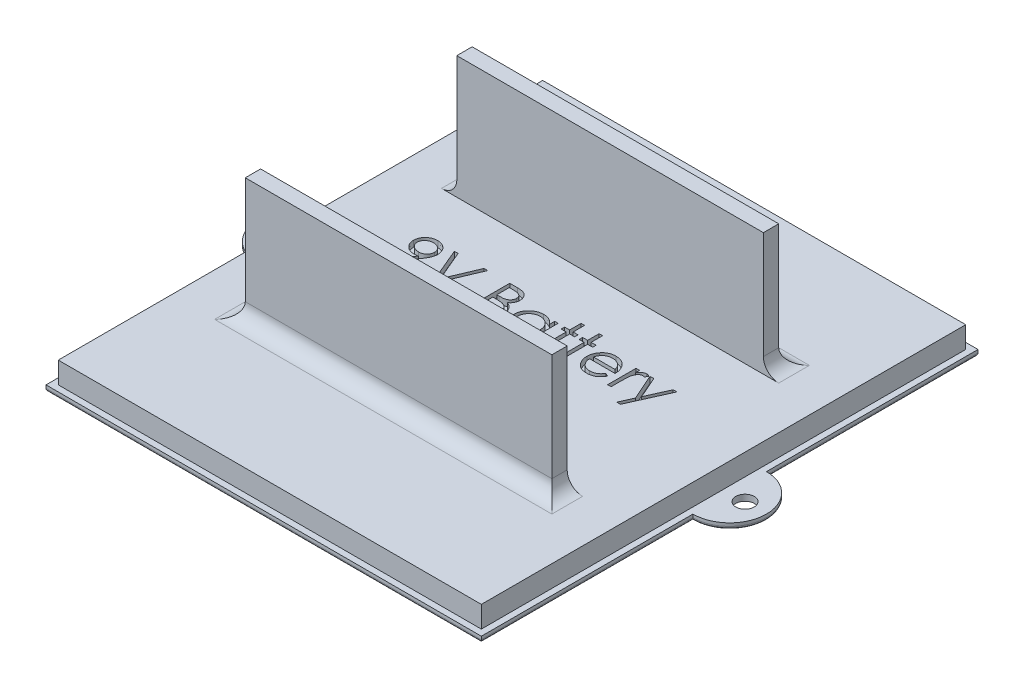
from build123d import *

# Parameters (mm, degrees)
SKETCH1_W            = 71
SKETCH1_H            = 81
BOSS_EXTRUDE1_DEPTH  = 4.5
TEXT_2_W             = 0.569871795
TEXT_2_H             = 6.512820513
CUT_EXTRUDE1_DEPTH   = 1
BOSS_EXTRUDE3_DEPTH  = 4.5
SKETCH5_R            = 1.5
CUT_EXTRUDE2_DEPTH   = 4.5
SKETCH61_W           = 89
SKETCH61_H           = 99
SKETCH61_W_2         = 69
SKETCH61_H_2         = 79
CUT_EXTRUDE21_DEPTH  = 3.5
SKETCH9_W            = 50
SKETCH9_H            = 2.5
TOP_TRACK_DEPTH      = 20
FILLET1_R            = 2.5
FILLET1_OF_MIRROR4_R = 2.5
FILLET2_R            = 0.5


with BuildPart() as part:
    # Sketch1 → Boss-Extrude1 (new body)
    with BuildSketch(Plane(origin=(0, 0, 0), x_dir=(1, 0, 0), z_dir=(0, 1, 0))):
        Rectangle(SKETCH1_W, SKETCH1_H)
    extrude(amount=BOSS_EXTRUDE1_DEPTH)

    # text 2 → Cut-Extrude1 (cut)
    with BuildSketch(Plane(origin=(0, 4.5, 0), x_dir=(1, 0, 0), z_dir=(0, 1, 0))):
        with BuildLine():
            Line((-21.152394286, 1.65489819), (-21.607782908, 1.971634969))
            Line((-21.607782908, 1.971634969), (-19.842197972, 4.552594504))
            add(Edge.make_bspline(
                [(-19.842197972, 4.552594504), (-19.954848307, 4.538818518), (-20.176663096, 4.511692833), (-20.400068981, 4.506709616), (-20.510016482, 4.504257164)],
                knots=[0, 0, 0, 0, 0.000340231, 0.000669933, 0.000669933, 0.000669933, 0.000669933], degree=3))
            add(Edge.make_bspline(
                [(-20.510016482, 4.504257164), (-20.576677054, 4.505964546), (-20.707525928, 4.509315987), (-20.899897641, 4.53588041), (-21.084747158, 4.576792785), (-21.261584418, 4.63784124), (-21.431074091, 4.71371142), (-21.592846171, 4.807794859), (-21.746682887, 4.918477702), (-21.890932045, 5.045174701), (-22.0221262, 5.184290596), (-22.139008468, 5.33153012), (-22.236147379, 5.488603667), (-22.316840613, 5.652307065), (-22.378037293, 5.82499323), (-22.422600754, 6.004697142), (-22.450037025, 6.192678264), (-22.453301099, 6.320631001), (-22.454958389, 6.385597308)],
                knots=[0, 0, 0, 0, 0.000199908, 0.000392402, 0.000581563, 0.000767006, 0.000952605, 0.001137838, 0.00132741, 0.001520307, 0.001712868, 0.00190041, 0.002083247, 0.002265863, 0.002446921, 0.002631721, 0.002820609, 0.003015434, 0.003015434, 0.003015434, 0.003015434], degree=3))
            add(Edge.make_bspline(
                [(-22.454958389, 6.385597308), (-22.451811628, 6.474440436), (-22.445635176, 6.648821471), (-22.395926438, 6.903608452), (-22.314174108, 7.144521181), (-22.200185482, 7.370926248), (-22.056612487, 7.579566817), (-21.884058331, 7.767542437), (-21.683572567, 7.932179529), (-21.459722332, 8.073701212), (-21.217781852, 8.187520421), (-20.964383001, 8.271411724), (-20.701467383, 8.320758023), (-20.523363181, 8.3272638), (-20.433694366, 8.330539216)],
                knots=[0, 0, 0, 0, 0.000266369, 0.000522829, 0.000775449, 0.001027459, 0.001280799, 0.00153288, 0.001790375, 0.002056814, 0.002325395, 0.002590482, 0.002855691, 0.0031246, 0.0031246, 0.0031246, 0.0031246], degree=3))
            add(Edge.make_bspline(
                [(-20.433694366, 8.330539216), (-20.345722519, 8.327218777), (-20.171898441, 8.320657903), (-19.91628553, 8.272608416), (-19.67146397, 8.191624738), (-19.438790923, 8.079711316), (-19.223363704, 7.939429097), (-19.029641875, 7.772270747), (-18.862046254, 7.578132148), (-18.720851499, 7.361708744), (-18.607512997, 7.129177221), (-18.525738998, 6.886454962), (-18.475400482, 6.635287568), (-18.469057145, 6.465117593), (-18.465855825, 6.379237132)],
                knots=[0, 0, 0, 0, 0.00026383, 0.000521303, 0.000777137, 0.001035436, 0.001293696, 0.001546188, 0.001800474, 0.002060496, 0.002319348, 0.002574378, 0.002827091, 0.003084573, 0.003084573, 0.003084573, 0.003084573], degree=3))
            add(Edge.make_bspline(
                [(-18.465855825, 6.379237132), (-18.467993795, 6.31257344), (-18.472330133, 6.177362817), (-18.502694576, 5.971930623), (-18.554256912, 5.762469107), (-18.612770709, 5.585174212), (-18.669253356, 5.438746024), (-18.72241398, 5.323082443), (-18.781400316, 5.20134158), (-18.85019579, 5.074799981), (-18.924150243, 4.941844525), (-19.007714931, 4.803808741), (-19.098983611, 4.660507396), (-19.163988959, 4.563901965), (-19.197276097, 4.514433446)],
                knots=[0, 0, 0, 0, 0.000199969, 0.000405586, 0.000621552, 0.000846414, 0.000965232, 0.001092194, 0.001228159, 0.001371001, 0.001524206, 0.001684548, 0.001854987, 0.002033856, 0.002033856, 0.002033856, 0.002033856], degree=3))
            Line((-19.197276097, 4.514433446), (-21.152394286, 1.65489819))
        make_face()
        with BuildLine():
            add(Edge.make_bspline(
                [(-20.404437555, 5.155539216), (-20.353938701, 5.156918769), (-20.2556346, 5.15960429), (-20.1116215, 5.175949629), (-19.975687588, 5.204931004), (-19.84746975, 5.24651391), (-19.725682371, 5.29669101), (-19.61225989, 5.360575613), (-19.507107382, 5.436805793), (-19.409520714, 5.52245825), (-19.322863172, 5.617618595), (-19.245677959, 5.717217631), (-19.180072358, 5.821692566), (-19.128250412, 5.932351771), (-19.085642683, 6.046501563), (-19.056218575, 6.165980179), (-19.039918428, 6.290165135), (-19.037139713, 6.374526986), (-19.035727619, 6.41739819)],
                knots=[0, 0, 0, 0, 0.000151506, 0.00029493, 0.000434147, 0.000567705, 0.000698823, 0.000828676, 0.000957177, 0.001087851, 0.001217486, 0.001342663, 0.001465499, 0.00158669, 0.001708626, 0.00183049, 0.00195498, 0.002083613, 0.002083613, 0.002083613, 0.002083613], degree=3))
            add(Edge.make_bspline(
                [(-19.035727619, 6.41739819), (-19.036942591, 6.460287297), (-19.039336841, 6.544805543), (-19.058545227, 6.669174357), (-19.092336703, 6.788360701), (-19.137676583, 6.903017081), (-19.1974033, 7.01220147), (-19.26907391, 7.117284666), (-19.354222783, 7.217600384), (-19.452198867, 7.310789325), (-19.557852985, 7.396691943), (-19.670448464, 7.472503823), (-19.78905724, 7.536042279), (-19.9129557, 7.588473268), (-20.04240199, 7.629388632), (-20.177319512, 7.658811565), (-20.318390033, 7.675088891), (-20.414150367, 7.677850043), (-20.462951177, 7.679257164)],
                knots=[0, 0, 0, 0, 0.000128633, 0.000253487, 0.000376322, 0.000499624, 0.000622565, 0.000748875, 0.00088064, 0.001016486, 0.00115396, 0.00128873, 0.001423042, 0.001556999, 0.001691769, 0.001829742, 0.00197064, 0.002117062, 0.002117062, 0.002117062, 0.002117062], degree=3))
            add(Edge.make_bspline(
                [(-20.462951177, 7.679257164), (-20.51132757, 7.67784777), (-20.606241653, 7.675082549), (-20.746058057, 7.658842505), (-20.880063319, 7.629190755), (-21.009134544, 7.58849222), (-21.133029323, 7.536038368), (-21.251632505, 7.472500494), (-21.364254321, 7.396709394), (-21.469807143, 7.310721735), (-21.56795623, 7.218034148), (-21.651641118, 7.116845213), (-21.723475751, 7.012256133), (-21.783120399, 6.903002554), (-21.828482109, 6.788364578), (-21.86226774, 6.669173306), (-21.881477697, 6.544805816), (-21.883871732, 6.460287389), (-21.885086594, 6.41739819)],
                knots=[0, 0, 0, 0, 0.000145151, 0.000284786, 0.000421516, 0.000556286, 0.000690243, 0.000824556, 0.000959325, 0.001096799, 0.001232645, 0.001363591, 0.001489901, 0.001612842, 0.001736144, 0.001858979, 0.001983833, 0.002112466, 0.002112466, 0.002112466, 0.002112466], degree=3))
            add(Edge.make_bspline(
                [(-21.885086594, 6.41739819), (-21.883987271, 6.374493601), (-21.881819204, 6.289877898), (-21.8609045, 6.165551443), (-21.825928192, 6.046374291), (-21.779084441, 5.931187637), (-21.717395842, 5.821111551), (-21.64169686, 5.716667909), (-21.552968227, 5.616672735), (-21.452396042, 5.52267965), (-21.342326664, 5.436406418), (-21.224766854, 5.361058439), (-21.101740435, 5.297427004), (-20.972814334, 5.246370493), (-20.838943997, 5.205346475), (-20.698926258, 5.176003043), (-20.55322417, 5.159761073), (-20.454508918, 5.156960003), (-20.404437555, 5.155539216)],
                knots=[0, 0, 0, 0, 0.000128633, 0.000253688, 0.000376872, 0.000500652, 0.000625933, 0.000754433, 0.000886902, 0.001026392, 0.001166853, 0.001305877, 0.001444692, 0.001581695, 0.001721324, 0.001864273, 0.002010225, 0.00216046, 0.00216046, 0.00216046, 0.00216046], degree=3))
        make_face(mode=Mode.SUBTRACT)
        Polygon((-17.570343004, 8.167718703), (-16.959766081, 8.167718703), (-14.843099414, 3.163532004), (-12.726432748, 8.167718703), (-12.115855825, 8.167718703), (-14.802394286, 1.817718703), (-14.883804543, 1.817718703), align=None)
        with BuildLine():
            Line((-8.533804543, 8.167718703), (-7.294842203, 8.167718703))
            add(Edge.make_bspline(
                [(-7.294842203, 8.167718703), (-7.234193392, 8.167399841), (-7.116640904, 8.166781808), (-6.945699916, 8.157196699), (-6.78559136, 8.144127184), (-6.636268801, 8.12338973), (-6.497801241, 8.098367506), (-6.369771385, 8.068065639), (-6.252586358, 8.03173164), (-6.112681822, 7.973953387), (-5.953168623, 7.888095639), (-5.780451539, 7.761225242), (-5.632760991, 7.606044916), (-5.505422958, 7.430997813), (-5.404183784, 7.238437198), (-5.330942345, 7.03295267), (-5.284573056, 6.817194653), (-5.279804326, 6.669070601), (-5.277394286, 6.594211091)],
                knots=[0, 0, 0, 0, 0.000181919, 0.000352604, 0.00051349, 0.000663703, 0.00080467, 0.000935486, 0.001058189, 0.001172283, 0.001389131, 0.001600035, 0.00181234, 0.002029124, 0.002247618, 0.002462475, 0.002682011, 0.002906326, 0.002906326, 0.002906326, 0.002906326], degree=3))
            add(Edge.make_bspline(
                [(-5.277394286, 6.594211091), (-5.279377697, 6.524084311), (-5.283275286, 6.386278576), (-5.32054572, 6.18472212), (-5.378894362, 5.992859195), (-5.460002457, 5.81139001), (-5.565416078, 5.64441474), (-5.690344742, 5.490586415), (-5.841069798, 5.356418068), (-5.953996819, 5.281410231), (-6.011358629, 5.243309648)],
                knots=[0, 0, 0, 0, 0.000210198, 0.000413059, 0.000612634, 0.000810762, 0.001007352, 0.001203448, 0.00140342, 0.001609859, 0.001609859, 0.001609859, 0.001609859], degree=3))
            add(Edge.make_bspline(
                [(-6.011358629, 5.243309648), (-5.939221853, 5.215614579), (-5.801206332, 5.16262705), (-5.611275995, 5.068945566), (-5.447636776, 4.967051451), (-5.309030525, 4.855777951), (-5.190489352, 4.73583768), (-5.086979015, 4.605471973), (-4.998657093, 4.462980227), (-4.922977932, 4.309848098), (-4.863925189, 4.14763922), (-4.819700334, 3.977875098), (-4.79435939, 3.801164476), (-4.790753241, 3.680903859), (-4.788932748, 3.620192661)],
                knots=[0, 0, 0, 0, 0.000231723, 0.000443344, 0.000634273, 0.000808894, 0.000975297, 0.001139193, 0.001307198, 0.001477294, 0.001650744, 0.001824133, 0.002002767, 0.002184886, 0.002184886, 0.002184886, 0.002184886], degree=3))
            add(Edge.make_bspline(
                [(-4.788932748, 3.620192661), (-4.790705025, 3.558204193), (-4.794192032, 3.436240146), (-4.819918552, 3.257070116), (-4.863477932, 3.085846998), (-4.92347844, 2.92146331), (-5.001787211, 2.764237066), (-5.097087946, 2.613990144), (-5.210719497, 2.472232144), (-5.33783356, 2.337387857), (-5.481637738, 2.216143157), (-5.63678775, 2.10816466), (-5.805237502, 2.019362519), (-5.984220406, 1.944766309), (-6.175744236, 1.887784677), (-6.378948967, 1.84792015), (-6.593659343, 1.821059583), (-6.740997034, 1.818851226), (-6.816556946, 1.817718703)],
                knots=[0, 0, 0, 0, 0.00018593, 0.000365823, 0.000541677, 0.000715127, 0.000889772, 0.001067625, 0.00124781, 0.001434053, 0.001622662, 0.001811078, 0.002000013, 0.002192776, 0.002391982, 0.002598291, 0.002813502, 0.003040053, 0.003040053, 0.003040053, 0.003040053], degree=3))
            Line((-6.816556946, 1.817718703), (-8.533804543, 1.817718703))
            Line((-8.533804543, 1.817718703), (-8.533804543, 8.167718703))
        make_face()
        with BuildLine():
            Line((-7.963932748, 7.516436651), (-7.963932748, 5.481180241))
            Line((-7.963932748, 5.481180241), (-7.581050135, 5.481180241))
            add(Edge.make_bspline(
                [(-7.581050135, 5.481180241), (-7.525081607, 5.481905816), (-7.416939004, 5.483307774), (-7.260330048, 5.487323726), (-7.114960372, 5.498568748), (-6.981080904, 5.509810538), (-6.85890247, 5.528088718), (-6.74869575, 5.549845855), (-6.648731152, 5.572856269), (-6.533452263, 5.611989481), (-6.402691342, 5.669824691), (-6.263294139, 5.759580737), (-6.140404458, 5.866486349), (-6.036632418, 5.98984138), (-5.951703035, 6.125670031), (-5.892713866, 6.271805086), (-5.852713794, 6.424604468), (-5.849100587, 6.529503298), (-5.847266081, 6.582762773)],
                knots=[0, 0, 0, 0, 0.000167928, 0.000324471, 0.00046984, 0.000605274, 0.000727423, 0.000840183, 0.000942303, 0.001034821, 0.00120505, 0.001369832, 0.0015303, 0.001691868, 0.001851786, 0.002008639, 0.002163205, 0.002322621, 0.002322621, 0.002322621, 0.002322621], degree=3))
            add(Edge.make_bspline(
                [(-5.847266081, 6.582762773), (-5.848220722, 6.618006673), (-5.850093355, 6.687141431), (-5.865430061, 6.787923831), (-5.891496946, 6.882708924), (-5.924978307, 6.972795667), (-5.971766356, 7.055367167), (-6.026854354, 7.133278394), (-6.093412678, 7.203876094), (-6.169172374, 7.269860756), (-6.256273732, 7.328361542), (-6.35466479, 7.379598355), (-6.465676719, 7.420856621), (-6.587438613, 7.456990212), (-6.721824729, 7.482368974), (-6.867284276, 7.503511548), (-7.025008694, 7.514275238), (-7.134129095, 7.51570011), (-7.190535312, 7.516436651)],
                knots=[0, 0, 0, 0, 0.000105701, 0.000207345, 0.000304853, 0.000400289, 0.000494806, 0.000588704, 0.000685913, 0.000785116, 0.000889546, 0.000999921, 0.001117093, 0.001244297, 0.001380505, 0.001526939, 0.001685086, 0.00185431, 0.00185431, 0.00185431, 0.00185431], degree=3))
            Line((-7.190535312, 7.516436651), (-7.963932748, 7.516436651))
        make_face(mode=Mode.SUBTRACT)
        with BuildLine():
            Line((-7.963932748, 4.82989819), (-7.963932748, 2.469000754))
            Line((-7.963932748, 2.469000754), (-7.152374254, 2.469000754))
            add(Edge.make_bspline(
                [(-7.152374254, 2.469000754), (-7.094282774, 2.469696981), (-6.982319105, 2.471038868), (-6.820664016, 2.47541956), (-6.670834671, 2.485384117), (-6.533514767, 2.501070159), (-6.407221518, 2.518085345), (-6.293469971, 2.540965812), (-6.191338034, 2.567180355), (-6.07291179, 2.607700924), (-5.939555425, 2.670650236), (-5.7958443, 2.765563189), (-5.668071018, 2.878635476), (-5.559567191, 3.009501563), (-5.470643626, 3.151798399), (-5.405954443, 3.30264782), (-5.366056746, 3.459557277), (-5.36122681, 3.566539741), (-5.358804543, 3.620192661)],
                knots=[0, 0, 0, 0, 0.000174287, 0.000335916, 0.000485092, 0.000624581, 0.000750506, 0.000867257, 0.000972467, 0.001066598, 0.001242424, 0.00141318, 0.001581671, 0.001752356, 0.001921441, 0.00208329, 0.002243101, 0.002403882, 0.002403882, 0.002403882, 0.002403882], degree=3))
            add(Edge.make_bspline(
                [(-5.358804543, 3.620192661), (-5.359305475, 3.653744865), (-5.360299259, 3.720308072), (-5.375286375, 3.818126772), (-5.397082967, 3.912879428), (-5.425261426, 4.004823329), (-5.466299602, 4.092296168), (-5.514208619, 4.177027955), (-5.570381448, 4.259130696), (-5.657910149, 4.36293007), (-5.785222178, 4.482522365), (-5.966118756, 4.599611834), (-6.171808497, 4.694041426), (-6.320992662, 4.734136191), (-6.398057347, 4.75484811)],
                knots=[0, 0, 0, 0, 0.000100563, 0.000199504, 0.000296087, 0.000392233, 0.000487296, 0.000585276, 0.000684069, 0.00078521, 0.000992212, 0.001205307, 0.001429016, 0.001668064, 0.001668064, 0.001668064, 0.001668064], degree=3))
            add(Edge.make_bspline(
                [(-6.398057347, 4.75484811), (-6.428952992, 4.761116619), (-6.495941124, 4.774708041), (-6.605174877, 4.789054874), (-6.729881382, 4.801836626), (-6.870348602, 4.811291154), (-7.026754257, 4.821063883), (-7.199432381, 4.824864488), (-7.387677795, 4.829398859), (-7.518292527, 4.829727489), (-7.586138277, 4.82989819)],
                knots=[0, 0, 0, 0, 9.4551e-05, 0.000205006, 0.000330312, 0.000470606, 0.000627319, 0.000800391, 0.000988691, 0.001192221, 0.001192221, 0.001192221, 0.001192221], degree=3))
            Line((-7.586138277, 4.82989819), (-7.963932748, 4.82989819))
        make_face(mode=Mode.SUBTRACT)
        with BuildLine():
            Line((1.072605714, 6.458103318), (1.072605714, 1.817718703))
            Line((1.072605714, 1.817718703), (0.502733919, 1.817718703))
            Line((0.502733919, 1.817718703), (0.502733919, 2.62037295))
            add(Edge.make_bspline(
                [(0.502733919, 2.62037295), (0.438474113, 2.547729686), (0.313070294, 2.405965444), (0.103627123, 2.220759217), (-0.118383714, 2.067672834), (-0.351884683, 1.944029415), (-0.596664924, 1.851152399), (-0.852181825, 1.78513751), (-1.118539616, 1.742694409), (-1.300426031, 1.738456198), (-1.392598613, 1.736308446)],
                knots=[0, 0, 0, 0, 0.000290762, 0.000567426, 0.000836293, 0.001098035, 0.001358135, 0.001619769, 0.001888723, 0.002165047, 0.002165047, 0.002165047, 0.002165047], degree=3))
            add(Edge.make_bspline(
                [(-1.392598613, 1.736308446), (-1.474546186, 1.738533436), (-1.63615043, 1.742921214), (-1.873874612, 1.776961394), (-2.102641979, 1.83162695), (-2.322668704, 1.907647135), (-2.532531025, 2.008486626), (-2.734025772, 2.129211462), (-2.926109084, 2.272976968), (-3.105853162, 2.437329533), (-3.271374077, 2.615846153), (-3.4166281, 2.806247359), (-3.53773726, 3.007709825), (-3.639010835, 3.217682833), (-3.717018488, 3.437782758), (-3.771399225, 3.667248477), (-3.805399749, 3.905808676), (-3.809785714, 4.068258954), (-3.812009671, 4.150631363)],
                knots=[0, 0, 0, 0, 0.00024577, 0.000484669, 0.00071884, 0.00095056, 0.001181567, 0.001416081, 0.001654206, 0.001900039, 0.002145792, 0.002383666, 0.00261709, 0.002849793, 0.003081935, 0.003316107, 0.003556266, 0.003803306, 0.003803306, 0.003803306, 0.003803306], degree=3))
            add(Edge.make_bspline(
                [(-3.812009671, 4.150631363), (-3.809736423, 4.231301225), (-3.805242334, 4.390781191), (-3.771762921, 4.625329686), (-3.715463805, 4.851241387), (-3.636455567, 5.067788984), (-3.535142306, 5.275234504), (-3.411901348, 5.473724664), (-3.266723793, 5.663806285), (-3.099351569, 5.841009796), (-2.918041343, 6.004695768), (-2.72407836, 6.146952179), (-2.52228755, 6.26980989), (-2.309538945, 6.367152626), (-2.088981483, 6.445909144), (-1.85865166, 6.500397529), (-1.619507796, 6.532505526), (-1.457146475, 6.537155113), (-1.374790119, 6.539513575)],
                knots=[0, 0, 0, 0, 0.000241958, 0.000478337, 0.000709106, 0.000939284, 0.001168551, 0.00140047, 0.001639115, 0.001884802, 0.002130726, 0.002370895, 0.002605409, 0.002838177, 0.003071519, 0.003306928, 0.003546915, 0.003793955, 0.003793955, 0.003793955, 0.003793955], degree=3))
            add(Edge.make_bspline(
                [(-1.374790119, 6.539513575), (-1.280084661, 6.536905082), (-1.094371726, 6.531789953), (-0.822722338, 6.489221862), (-0.565738785, 6.417306357), (-0.321437318, 6.31948461), (-0.090695216, 6.189493345), (0.124303055, 6.025518273), (0.325807575, 5.828593548), (0.442611819, 5.677335741), (0.502733919, 5.59947952)],
                knots=[0, 0, 0, 0, 0.000284009, 0.000556928, 0.000822345, 0.001083124, 0.001344564, 0.001614238, 0.001892186, 0.002187002, 0.002187002, 0.002187002, 0.002187002], degree=3))
            Line((0.502733919, 5.59947952), (0.502733919, 6.458103318))
            Line((0.502733919, 6.458103318), (1.072605714, 6.458103318))
        make_face()
        with BuildLine():
            add(Edge.make_bspline(
                [(-1.367157908, 5.96964178), (-1.450459635, 5.966677894), (-1.614883995, 5.960827655), (-1.856263827, 5.915155743), (-2.087246736, 5.839165121), (-2.306677471, 5.735239386), (-2.511089807, 5.604558679), (-2.693776895, 5.446495597), (-2.856232939, 5.265362729), (-2.992863647, 5.061977472), (-3.104243548, 4.843940078), (-3.182560878, 4.616021454), (-3.234212227, 4.382332424), (-3.239489114, 4.223831551), (-3.242137876, 4.144271187)],
                knots=[0, 0, 0, 0, 0.000249786, 0.000493037, 0.00073399, 0.000977521, 0.001219572, 0.001459505, 0.001700041, 0.001947359, 0.002192545, 0.00243231, 0.002668812, 0.002907172, 0.002907172, 0.002907172, 0.002907172], degree=3))
            add(Edge.make_bspline(
                [(-3.242137876, 4.144271187), (-3.238754427, 4.065186278), (-3.23200079, 3.907326447), (-3.183467387, 3.673318829), (-3.102042474, 3.445346495), (-2.990931875, 3.225344407), (-2.851800427, 3.021084682), (-2.690531014, 2.836499031), (-2.505564075, 2.677767921), (-2.300681313, 2.544894037), (-2.081863995, 2.437556321), (-1.851751005, 2.362870089), (-1.614668061, 2.314650402), (-1.453464541, 2.309017994), (-1.372246049, 2.306180241)],
                knots=[0, 0, 0, 0, 0.000237176, 0.000473422, 0.000713608, 0.000961638, 0.001210723, 0.001453162, 0.001694889, 0.001939391, 0.002184022, 0.002423766, 0.002663507, 0.002906945, 0.002906945, 0.002906945, 0.002906945], degree=3))
            add(Edge.make_bspline(
                [(-1.372246049, 2.306180241), (-1.289793108, 2.30919189), (-1.125802387, 2.315181761), (-0.883706446, 2.361049199), (-0.648765584, 2.436829733), (-0.424180184, 2.541875292), (-0.214963775, 2.672063638), (-0.027189054, 2.824476503), (0.131589917, 3.001737994), (0.266196509, 3.196549559), (0.371743336, 3.410112752), (0.448625615, 3.637504784), (0.494080558, 3.87873357), (0.499809582, 4.043586695), (0.502733919, 4.127734728)],
                knots=[0, 0, 0, 0, 0.000247246, 0.000491749, 0.00073633, 0.000986158, 0.001233581, 0.001473979, 0.001709031, 0.001945074, 0.002182295, 0.002421234, 0.002663235, 0.00291556, 0.00291556, 0.00291556, 0.00291556], degree=3))
            add(Edge.make_bspline(
                [(0.502733919, 4.127734728), (0.500992828, 4.191847649), (0.49756581, 4.318042167), (0.471384634, 4.503330663), (0.429737839, 4.680647566), (0.371052645, 4.850179302), (0.293961315, 5.010988544), (0.200983225, 5.164229938), (0.090483338, 5.309106478), (-0.035759554, 5.443623193), (-0.173944993, 5.566316917), (-0.320166516, 5.675834897), (-0.476156529, 5.765803099), (-0.639291724, 5.840263691), (-0.809855145, 5.899516721), (-0.989234698, 5.939045822), (-1.175523718, 5.966188119), (-1.302607275, 5.968478438), (-1.367157908, 5.96964178)],
                knots=[0, 0, 0, 0, 0.000192284, 0.000378475, 0.000560202, 0.000738015, 0.000915535, 0.001094205, 0.001274839, 0.001461134, 0.001646738, 0.001828644, 0.002008199, 0.002185797, 0.002366014, 0.002548692, 0.002736143, 0.002929643, 0.002929643, 0.002929643, 0.002929643], degree=3))
        make_face(mode=Mode.SUBTRACT)
        Polygon((2.945041611, 8.330539216), (3.514913406, 8.330539216), (3.514913406, 6.458103318), (4.32901597, 6.458103318), (4.32901597, 5.888231523), (3.514913406, 5.888231523), (3.514913406, 1.817718703), (2.945041611, 1.817718703), (2.945041611, 5.888231523), (2.130939047, 5.888231523), (2.130939047, 6.458103318), (2.945041611, 6.458103318), align=None)
        Polygon((5.875810842, 8.330539216), (6.445682637, 8.330539216), (6.445682637, 6.458103318), (7.259785201, 6.458103318), (7.259785201, 5.888231523), (6.445682637, 5.888231523), (6.445682637, 1.817718703), (5.875810842, 1.817718703), (5.875810842, 5.888231523), (5.061708278, 5.888231523), (5.061708278, 6.458103318), (5.875810842, 6.458103318), align=None)
        with BuildLine():
            Line((12.045181836, 3.283103318), (12.551451868, 3.01724795))
            add(Edge.make_bspline(
                [(12.551451868, 3.01724795), (12.511108331, 2.945686477), (12.432615784, 2.806456191), (12.29763157, 2.615172672), (12.156131667, 2.443091816), (12.001728753, 2.294810872), (11.839042336, 2.165540502), (11.667170234, 2.052441877), (11.485217664, 1.956069705), (11.293176021, 1.874875833), (11.089432549, 1.812447179), (10.873493512, 1.768352378), (10.644945228, 1.741095877), (10.488288587, 1.737929693), (10.408072461, 1.736308446)],
                knots=[0, 0, 0, 0, 0.000246306, 0.000479213, 0.000701365, 0.000913669, 0.001120076, 0.001323999, 0.001529994, 0.001736945, 0.001948585, 0.002168121, 0.002397377, 0.002637956, 0.002637956, 0.002637956, 0.002637956], degree=3))
            add(Edge.make_bspline(
                [(10.408072461, 1.736308446), (10.318914873, 1.73838975), (10.144994248, 1.742449771), (9.891829278, 1.777451814), (9.653469476, 1.834551664), (9.429928243, 1.914317718), (9.221753014, 2.018507292), (9.028530034, 2.14543378), (8.84924318, 2.294445157), (8.689542115, 2.466832133), (8.54577107, 2.651312255), (8.418905654, 2.843546503), (8.312847172, 3.04305121), (8.226573151, 3.248556304), (8.156895753, 3.458766511), (8.108333305, 3.675594459), (8.080339333, 3.898453304), (8.076049554, 4.049215614), (8.073887765, 4.125190658)],
                knots=[0, 0, 0, 0, 0.000267373, 0.000521567, 0.000764991, 0.001001583, 0.001231976, 0.001461655, 0.001693741, 0.001929511, 0.002165136, 0.002394815, 0.002619591, 0.002841906, 0.003062747, 0.003283088, 0.003507446, 0.003735368, 0.003735368, 0.003735368, 0.003735368], degree=3))
            add(Edge.make_bspline(
                [(8.073887765, 4.125190658), (8.07580935, 4.196482707), (8.079617678, 4.337774135), (8.103622106, 4.546898765), (8.14616401, 4.750150386), (8.204541054, 4.947697885), (8.279926887, 5.139210499), (8.372151056, 5.324804786), (8.481357227, 5.504283254), (8.565671935, 5.617500368), (8.608142573, 5.6745296)],
                knots=[0, 0, 0, 0, 0.000213887, 0.000423896, 0.00063046, 0.000836125, 0.00104116, 0.001247092, 0.001457178, 0.00167041, 0.00167041, 0.00167041, 0.00167041], degree=3))
            add(Edge.make_bspline(
                [(8.608142573, 5.6745296), (8.665669369, 5.74323455), (8.778900658, 5.878468052), (8.970410045, 6.056156157), (9.177783259, 6.205007006), (9.398421494, 6.328391382), (9.634889097, 6.422142141), (9.884007383, 6.492005898), (10.148612946, 6.531154575), (10.329506704, 6.536684216), (10.422064848, 6.539513575)],
                knots=[0, 0, 0, 0, 0.000268643, 0.000528777, 0.000781195, 0.001032868, 0.001285142, 0.001542524, 0.001807514, 0.002085171, 0.002085171, 0.002085171, 0.002085171], degree=3))
            add(Edge.make_bspline(
                [(10.422064848, 6.539513575), (10.51721979, 6.537056943), (10.703892093, 6.532237592), (10.976093227, 6.487558387), (11.233650527, 6.416705895), (11.476460927, 6.316641161), (11.704549046, 6.187537403), (11.916432308, 6.027622919), (12.115734338, 5.841807246), (12.231682759, 5.698908281), (12.29068464, 5.62619226)],
                knots=[0, 0, 0, 0, 0.000285279, 0.000559653, 0.00082507, 0.001085153, 0.001345486, 0.001609052, 0.001879912, 0.002160548, 0.002160548, 0.002160548, 0.002160548], degree=3))
            add(Edge.make_bspline(
                [(12.29068464, 5.62619226), (12.330829228, 5.571394334), (12.41085119, 5.462163233), (12.511085214, 5.284052705), (12.598093631, 5.097706341), (12.667640575, 4.900111945), (12.723955098, 4.693610707), (12.764698184, 4.476726376), (12.788591634, 4.249523536), (12.793288271, 4.094716786), (12.795682637, 4.015795626)],
                knots=[0, 0, 0, 0, 0.000203625, 0.000405895, 0.000611921, 0.000819933, 0.001033468, 0.001253512, 0.00148122, 0.001718038, 0.001718038, 0.001718038, 0.001718038], degree=3))
            Line((12.795682637, 4.015795626), (8.64375956, 4.015795626))
            add(Edge.make_bspline(
                [(8.64375956, 4.015795626), (8.646552846, 3.954653355), (8.65204573, 3.834419545), (8.677654633, 3.658486839), (8.718020265, 3.490895204), (8.774751279, 3.332901685), (8.843452555, 3.182442739), (8.927609498, 3.040634472), (9.028011261, 2.908122799), (9.139999315, 2.783722421), (9.264653617, 2.672940754), (9.395795172, 2.573786817), (9.535302069, 2.490682377), (9.682074306, 2.423227435), (9.835874545, 2.370420261), (9.996751242, 2.334374358), (10.164387824, 2.310231464), (10.278661942, 2.307546929), (10.336838486, 2.306180241)],
                knots=[0, 0, 0, 0, 0.00018353, 0.000360905, 0.000532442, 0.00069981, 0.000863725, 0.001027995, 0.001193359, 0.001361754, 0.001529296, 0.00169288, 0.001854313, 0.002015385, 0.002176693, 0.00234116, 0.002509362, 0.002683798, 0.002683798, 0.002683798, 0.002683798], degree=3))
            add(Edge.make_bspline(
                [(10.336838486, 2.306180241), (10.393718426, 2.30728343), (10.506579136, 2.309472367), (10.67465612, 2.330757406), (10.840009263, 2.365174906), (11.00195419, 2.412146745), (11.157204153, 2.469436177), (11.300978222, 2.538565647), (11.433203756, 2.61503733), (11.556787396, 2.702503455), (11.676659055, 2.809561166), (11.795571852, 2.943157402), (11.92307378, 3.10115906), (12.00288347, 3.220077625), (12.045181836, 3.283103318)],
                knots=[0, 0, 0, 0, 0.000170571, 0.000338446, 0.00050734, 0.000676826, 0.00084387, 0.00100318, 0.001154808, 0.001301644, 0.001456613, 0.00163579, 0.001837627, 0.002065222, 0.002065222, 0.002065222, 0.002065222], degree=3))
        make_face()
        with BuildLine():
            add(Edge.make_bspline(
                [(12.225810842, 4.585667421), (12.20495268, 4.661255777), (12.164807433, 4.806739032), (12.080921458, 5.008198933), (11.986448805, 5.187246982), (11.874649379, 5.342512888), (11.747978262, 5.480404976), (11.601664859, 5.600907266), (11.43758831, 5.708707498), (11.256596726, 5.799698462), (11.064932344, 5.877150063), (10.86426111, 5.929084201), (10.659504838, 5.964661514), (10.521012633, 5.967974596), (10.451321659, 5.96964178)],
                knots=[0, 0, 0, 0, 0.000235027, 0.000452352, 0.000653261, 0.000841057, 0.001024689, 0.001213453, 0.001408203, 0.001612435, 0.001820303, 0.002027035, 0.00223323, 0.002442092, 0.002442092, 0.002442092, 0.002442092], degree=3))
            add(Edge.make_bspline(
                [(10.451321659, 5.96964178), (10.394444821, 5.968532033), (10.282011269, 5.966338296), (10.116365045, 5.945528205), (9.95728902, 5.911129629), (9.803609427, 5.864021779), (9.657340137, 5.801231886), (9.515472486, 5.727602318), (9.381613767, 5.63771973), (9.297900274, 5.569214379), (9.255608518, 5.534605722)],
                knots=[0, 0, 0, 0, 0.000170571, 0.000337184, 0.000499855, 0.000658375, 0.000818556, 0.000976739, 0.001137263, 0.001301158, 0.001301158, 0.001301158, 0.001301158], degree=3))
            add(Edge.make_bspline(
                [(9.255608518, 5.534605722), (9.225322135, 5.507220321), (9.164029878, 5.451798943), (9.082132074, 5.356314525), (9.003717788, 5.253350977), (8.932355304, 5.138969108), (8.866900254, 5.014471409), (8.80565001, 4.880907985), (8.750520376, 4.737265306), (8.719503148, 4.637166738), (8.703545217, 4.585667421)],
                knots=[0, 0, 0, 0, 0.00012238, 0.000247668, 0.000376652, 0.00051041, 0.000651531, 0.000798389, 0.000950996, 0.00111271, 0.00111271, 0.00111271, 0.00111271], degree=3))
            Line((8.703545217, 4.585667421), (12.225810842, 4.585667421))
        make_face(mode=Mode.SUBTRACT)
        with BuildLine():
            Line((13.772605714, 6.458103318), (14.342477509, 6.458103318))
            Line((14.342477509, 6.458103318), (14.342477509, 5.775020385))
            add(Edge.make_bspline(
                [(14.342477509, 5.775020385), (14.384548542, 5.838621674), (14.465009068, 5.960258644), (14.598745382, 6.12113009), (14.735729998, 6.25432596), (14.876618695, 6.360468059), (15.022447533, 6.439957574), (15.170016003, 6.498183509), (15.321645784, 6.532613781), (15.42353956, 6.537210563), (15.474588887, 6.539513575)],
                knots=[0, 0, 0, 0, 0.000228641, 0.000437274, 0.000626196, 0.00080072, 0.000964674, 0.001122945, 0.001275403, 0.001428476, 0.001428476, 0.001428476, 0.001428476], degree=3))
            add(Edge.make_bspline(
                [(15.474588887, 6.539513575), (15.514188079, 6.537353619), (15.595665991, 6.532909371), (15.719005833, 6.501684017), (15.846084667, 6.451831033), (15.927985855, 6.404949487), (15.970682637, 6.380509167)],
                knots=[0, 0, 0, 0, 0.000118736, 0.000244307, 0.000379658, 0.000527066, 0.000527066, 0.000527066, 0.000527066], degree=3))
            Line((15.970682637, 6.380509167), (15.657761964, 5.886959488))
            add(Edge.make_bspline(
                [(15.657761964, 5.886959488), (15.630349883, 5.899188257), (15.578316505, 5.9224008), (15.502198935, 5.949872733), (15.432019938, 5.966048752), (15.387309482, 5.968499339), (15.36646589, 5.96964178)],
                knots=[0, 0, 0, 0, 9.0027e-05, 0.000170889, 0.000242497, 0.000305034, 0.000305034, 0.000305034, 0.000305034], degree=3))
            add(Edge.make_bspline(
                [(15.36646589, 5.96964178), (15.320735488, 5.966593712), (15.227458723, 5.960376537), (15.090508274, 5.911501843), (14.957616916, 5.832534622), (14.8520769, 5.744957033), (14.770357384, 5.660506029), (14.712045832, 5.586758213), (14.658555705, 5.504065553), (14.607446877, 5.413841698), (14.560880886, 5.31454612), (14.517420272, 5.207170862), (14.478124906, 5.091591557), (14.455718035, 5.011068984), (14.444240329, 4.969822068)],
                knots=[0, 0, 0, 0, 0.000136961, 0.000279361, 0.000430989, 0.000599071, 0.000689036, 0.000783201, 0.000880576, 0.000984237, 0.001094053, 0.001209325, 0.001331612, 0.001460037, 0.001460037, 0.001460037, 0.001460037], degree=3))
            add(Edge.make_bspline(
                [(14.444240329, 4.969822068), (14.435654416, 4.933033482), (14.416637269, 4.851549559), (14.398146908, 4.714845807), (14.379877925, 4.553331454), (14.367002632, 4.366556921), (14.355068184, 4.15498863), (14.348337035, 3.918304272), (14.342707051, 3.656260906), (14.342556344, 3.47306458), (14.342477509, 3.377233927)],
                knots=[0, 0, 0, 0, 0.000113275, 0.000250896, 0.000413424, 0.000600936, 0.000812404, 0.001049125, 0.001311214, 0.001598697, 0.001598697, 0.001598697, 0.001598697], degree=3))
            Line((14.342477509, 3.377233927), (14.342477509, 1.817718703))
            Line((14.342477509, 1.817718703), (13.772605714, 1.817718703))
            Line((13.772605714, 1.817718703), (13.772605714, 6.458103318))
        make_face()
        Polygon((16.052092893, 6.458103318), (16.666485922, 6.458103318), (18.237449464, 2.904036812), (19.832581675, 6.458103318), (20.44824674, 6.458103318), (17.598887765, 0.108103318), (16.983222701, 0.108103318), (17.928344897, 2.213321667), align=None)
        Polygon((-13.052073773, -3.415614631), (-12.482201978, -3.415614631), (-12.482201978, -6.020742836), (-9.225791722, -6.020742836), (-9.225791722, -3.415614631), (-8.655919927, -3.415614631), (-8.655919927, -9.765614631), (-9.225791722, -9.765614631), (-9.225791722, -6.672024887), (-12.482201978, -6.672024887), (-12.482201978, -9.765614631), (-13.052073773, -9.765614631), align=None)
        with BuildLine():
            add(Edge.make_bspline(
                [(-4.94920919, -5.043819759), (-4.862139309, -5.045673761), (-4.691416552, -5.049309007), (-4.441393673, -5.088161873), (-4.202733212, -5.147574949), (-3.974521121, -5.229710497), (-3.759680128, -5.339804893), (-3.555080871, -5.471176036), (-3.361284297, -5.62681017), (-3.24512823, -5.747202665), (-3.186168325, -5.808312948)],
                knots=[0, 0, 0, 0, 0.000261018, 0.000511793, 0.000757062, 0.000998109, 0.001237606, 0.001479657, 0.001726593, 0.001981143, 0.001981143, 0.001981143, 0.001981143], degree=3))
            add(Edge.make_bspline(
                [(-3.186168325, -5.808312948), (-3.135401065, -5.866758322), (-3.034849032, -5.982517992), (-2.905915514, -6.170216032), (-2.794842112, -6.364598786), (-2.705827883, -6.568247507), (-2.635642197, -6.779384411), (-2.585811577, -6.998735202), (-2.556171709, -7.225815461), (-2.552174897, -7.38003671), (-2.550150696, -7.458142675)],
                knots=[0, 0, 0, 0, 0.000232086, 0.000459681, 0.000681833, 0.000902819, 0.001125265, 0.001348369, 0.001576673, 0.001810949, 0.001810949, 0.001810949, 0.001810949], degree=3))
            add(Edge.make_bspline(
                [(-2.550150696, -7.458142675), (-2.551931123, -7.536701352), (-2.555449328, -7.691936959), (-2.588729889, -7.920572094), (-2.640493431, -8.142268415), (-2.714574051, -8.35609776), (-2.809566621, -8.562713747), (-2.925482583, -8.761213929), (-3.063135374, -8.951989942), (-3.219171197, -9.133421849), (-3.391622458, -9.300637696), (-3.578704612, -9.446376127), (-3.776741216, -9.571238036), (-3.988365586, -9.671815533), (-4.211645169, -9.751117418), (-4.447061564, -9.806816019), (-4.694249049, -9.840492217), (-4.863027008, -9.8448167), (-4.94920919, -9.847024887)],
                knots=[0, 0, 0, 0, 0.000235546, 0.000465451, 0.000691608, 0.000917687, 0.001143082, 0.001372814, 0.001606155, 0.001847882, 0.00208988, 0.002325505, 0.002558096, 0.002790799, 0.003026963, 0.003267616, 0.003515337, 0.003773814, 0.003773814, 0.003773814, 0.003773814], degree=3))
            add(Edge.make_bspline(
                [(-4.94920919, -9.847024887), (-5.03581361, -9.844809288), (-5.205432741, -9.840469926), (-5.453492737, -9.806946856), (-5.689331045, -9.751143087), (-5.912902931, -9.671554922), (-6.125437154, -9.571234821), (-6.324621227, -9.446753613), (-6.511855359, -9.300594474), (-6.684343102, -9.13343356), (-6.840369143, -8.951986925), (-6.978024458, -8.761214712), (-7.093939764, -8.562713543), (-7.188932506, -8.356097814), (-7.263013081, -8.142268401), (-7.314776634, -7.920572098), (-7.348057192, -7.691936958), (-7.351575398, -7.536701351), (-7.353355825, -7.458142675)],
                knots=[0, 0, 0, 0, 0.000259748, 0.000508729, 0.000749382, 0.000985546, 0.001219397, 0.001453067, 0.001688693, 0.00193069, 0.002172417, 0.002405759, 0.00263549, 0.002860885, 0.003086964, 0.003313122, 0.003543026, 0.003778572, 0.003778572, 0.003778572, 0.003778572], degree=3))
            add(Edge.make_bspline(
                [(-7.353355825, -7.458142675), (-7.351317819, -7.380461228), (-7.347282917, -7.226665312), (-7.317672851, -7.000011931), (-7.268036613, -6.781032382), (-7.197766793, -6.570710447), (-7.10793209, -6.367954156), (-6.998419467, -6.173091105), (-6.868170748, -5.98624181), (-6.768018636, -5.870631751), (-6.717338196, -5.812129054)],
                knots=[0, 0, 0, 0, 0.000233005, 0.000461309, 0.000684413, 0.000905652, 0.001125475, 0.001348734, 0.001575285, 0.001807372, 0.001807372, 0.001807372, 0.001807372], degree=3))
            add(Edge.make_bspline(
                [(-6.717338196, -5.812129054), (-6.658467181, -5.750488807), (-6.542686971, -5.629262415), (-6.347925708, -5.474081978), (-6.143829775, -5.339977102), (-5.926614552, -5.232070254), (-5.698589939, -5.1470918), (-5.458706456, -5.088008651), (-5.207835163, -5.049448993), (-5.036276994, -5.04571487), (-4.94920919, -5.043819759)],
                knots=[0, 0, 0, 0, 0.000255448, 0.000502383, 0.000745126, 0.000986896, 0.001228382, 0.00147365, 0.001726942, 0.00198796, 0.00198796, 0.00198796, 0.00198796], degree=3))
        make_face()
        with BuildLine():
            add(Edge.make_bspline(
                [(-4.95175326, -5.613691554), (-5.013325784, -5.615441599), (-5.134881346, -5.618896511), (-5.31380545, -5.645174453), (-5.486054015, -5.686807781), (-5.651953832, -5.745960855), (-5.810945445, -5.822340286), (-5.963181075, -5.916154025), (-6.109108501, -6.026159532), (-6.245873102, -6.152184665), (-6.371389583, -6.28985084), (-6.481113912, -6.436532863), (-6.574413747, -6.58985152), (-6.652138036, -6.749966246), (-6.710026791, -6.918499625), (-6.752069275, -7.093543056), (-6.778322426, -7.275453169), (-6.781744855, -7.399116731), (-6.78348403, -7.461958781)],
                knots=[0, 0, 0, 0, 0.00018466, 0.000364553, 0.000541334, 0.000715547, 0.00089192, 0.001069504, 0.001251152, 0.001439314, 0.001626619, 0.001809283, 0.001987953, 0.002164326, 0.002342139, 0.002521392, 0.002703804, 0.002892275, 0.002892275, 0.002892275, 0.002892275], degree=3))
            add(Edge.make_bspline(
                [(-6.78348403, -7.461958781), (-6.780568793, -7.543151745), (-6.774782592, -7.704304595), (-6.727728663, -7.941633346), (-6.649013555, -8.169474706), (-6.542719491, -8.386493007), (-6.409539637, -8.58728414), (-6.252627387, -8.766302404), (-6.073666788, -8.920853805), (-5.874791138, -9.049089053), (-5.660062589, -9.150978896), (-5.432811835, -9.223185609), (-5.19579229, -9.270124251), (-5.033811535, -9.27478964), (-4.95175326, -9.277153092)],
                knots=[0, 0, 0, 0, 0.000243438, 0.000483178, 0.000722527, 0.000964873, 0.001206187, 0.00144324, 0.001676828, 0.001913224, 0.002151068, 0.002387605, 0.002627106, 0.002873007, 0.002873007, 0.002873007, 0.002873007], degree=3))
            add(Edge.make_bspline(
                [(-4.95175326, -9.277153092), (-4.869699705, -9.274775869), (-4.707728267, -9.270083298), (-4.471038046, -9.22342201), (-4.244408412, -9.150662512), (-4.029902894, -9.049203645), (-3.831117771, -8.920366836), (-3.650870079, -8.767175123), (-3.495297599, -8.586809993), (-3.362249487, -8.386227047), (-3.254214683, -8.169811152), (-3.175868017, -7.941591295), (-3.128700968, -7.704315304), (-3.122930036, -7.543155333), (-3.120022491, -7.461958781)],
                knots=[0, 0, 0, 0, 0.000245901, 0.000485402, 0.000720729, 0.000958572, 0.001194969, 0.001429521, 0.001665736, 0.001907051, 0.002149959, 0.002389308, 0.002629049, 0.002872487, 0.002872487, 0.002872487, 0.002872487], degree=3))
            add(Edge.make_bspline(
                [(-3.120022491, -7.461958781), (-3.121761067, -7.399116355), (-3.125182318, -7.275452054), (-3.151444039, -7.093547317), (-3.193454804, -6.918483992), (-3.251460453, -6.750023929), (-3.328847021, -6.589436956), (-3.423946059, -6.436983023), (-3.533222348, -6.289342718), (-3.660253411, -6.152629684), (-3.796875253, -6.026110404), (-3.942861823, -5.916111368), (-4.094871712, -5.822752588), (-4.253401427, -5.745307552), (-4.419322514, -5.687345948), (-4.591329734, -5.64493406), (-4.769490432, -5.61900756), (-4.89061041, -5.615474889), (-4.95175326, -5.613691554)],
                knots=[0, 0, 0, 0, 0.000188472, 0.000370883, 0.000550137, 0.000727949, 0.000904322, 0.001083656, 0.001266321, 0.001454483, 0.001642645, 0.001824293, 0.002001877, 0.002177105, 0.002352516, 0.002528062, 0.002707955, 0.002891344, 0.002891344, 0.002891344, 0.002891344], degree=3))
        make_face(mode=Mode.SUBTRACT)
        with Locations((-1.206881465, -6.509204375)):
            Rectangle(TEXT_2_W, TEXT_2_H)
        with BuildLine():
            Line((5.102413406, -3.252794118), (5.102413406, -9.765614631))
            Line((5.102413406, -9.765614631), (4.532541611, -9.765614631))
            Line((4.532541611, -9.765614631), (4.532541611, -8.962960384))
            add(Edge.make_bspline(
                [(4.532541611, -8.962960384), (4.468281805, -9.035603647), (4.342877986, -9.177367889), (4.133434815, -9.362574116), (3.911423978, -9.5156605), (3.67792301, -9.639303918), (3.433142768, -9.732180935), (3.177625867, -9.798195823), (2.911268076, -9.840638924), (2.729381661, -9.844877135), (2.637209079, -9.847024887)],
                knots=[0, 0, 0, 0, 0.000290762, 0.000567426, 0.000836293, 0.001098035, 0.001358135, 0.001619769, 0.001888723, 0.002165047, 0.002165047, 0.002165047, 0.002165047], degree=3))
            add(Edge.make_bspline(
                [(2.637209079, -9.847024887), (2.555261506, -9.844799897), (2.393657263, -9.840412119), (2.15593308, -9.80637194), (1.927165713, -9.751706383), (1.707138988, -9.675686198), (1.497276667, -9.574846707), (1.295781921, -9.454121872), (1.103698608, -9.310356366), (0.92395453, -9.1460038), (0.758433615, -8.96748718), (0.613179592, -8.777085974), (0.492070433, -8.575623508), (0.390796858, -8.3656505), (0.312789204, -8.145550575), (0.258408468, -7.916084856), (0.224407943, -7.677524657), (0.220021979, -7.515074379), (0.217798022, -7.43270197)],
                knots=[0, 0, 0, 0, 0.00024577, 0.000484669, 0.00071884, 0.00095056, 0.001181567, 0.001416081, 0.001654206, 0.001900039, 0.002145792, 0.002383666, 0.00261709, 0.002849793, 0.003081935, 0.003316107, 0.003556266, 0.003803306, 0.003803306, 0.003803306, 0.003803306], degree=3))
            add(Edge.make_bspline(
                [(0.217798022, -7.43270197), (0.22007127, -7.352032108), (0.224565358, -7.192552142), (0.258044772, -6.958003648), (0.314343887, -6.732091946), (0.393352125, -6.515544349), (0.494665386, -6.308098829), (0.617906344, -6.10960867), (0.763083899, -5.919527049), (0.930456123, -5.742323537), (1.111766349, -5.578637565), (1.305729332, -5.436381154), (1.507520143, -5.313523443), (1.720268748, -5.216180707), (1.940826209, -5.137424189), (2.171156032, -5.082935804), (2.410299896, -5.050827807), (2.572661218, -5.046178221), (2.655017573, -5.043819759)],
                knots=[0, 0, 0, 0, 0.000241958, 0.000478337, 0.000709106, 0.000939284, 0.001168551, 0.00140047, 0.001639115, 0.001884802, 0.002130726, 0.002370895, 0.002605409, 0.002838177, 0.003071519, 0.003306928, 0.003546915, 0.003793955, 0.003793955, 0.003793955, 0.003793955], degree=3))
            add(Edge.make_bspline(
                [(2.655017573, -5.043819759), (2.749753781, -5.046662919), (2.93571043, -5.052243726), (3.207669176, -5.09888242), (3.464912412, -5.177192213), (3.708921118, -5.28440068), (3.938240592, -5.423739186), (4.154551783, -5.592016813), (4.354092954, -5.793996064), (4.472151832, -5.945691347), (4.532541611, -6.023286906)],
                knots=[0, 0, 0, 0, 0.000284074, 0.000557606, 0.0008248, 0.001089053, 0.001354982, 0.001627758, 0.001909292, 0.002204108, 0.002204108, 0.002204108, 0.002204108], degree=3))
            Line((4.532541611, -6.023286906), (4.532541611, -3.252794118))
            Line((4.532541611, -3.252794118), (5.102413406, -3.252794118))
        make_face()
        with BuildLine():
            add(Edge.make_bspline(
                [(2.662649784, -5.613691554), (2.579348057, -5.616655439), (2.414923697, -5.622505678), (2.173543865, -5.668177591), (1.942560956, -5.744168212), (1.723130222, -5.848093947), (1.518717886, -5.978774655), (1.336030797, -6.136837736), (1.173574753, -6.317970604), (1.036944045, -6.521355862), (0.925564144, -6.739393256), (0.847246815, -6.967311879), (0.795595466, -7.20100091), (0.790318578, -7.359501783), (0.787669816, -7.439062147)],
                knots=[0, 0, 0, 0, 0.000249786, 0.000493037, 0.00073399, 0.000977521, 0.001219572, 0.001459505, 0.001700041, 0.001947359, 0.002192545, 0.00243231, 0.002668812, 0.002907172, 0.002907172, 0.002907172, 0.002907172], degree=3))
            add(Edge.make_bspline(
                [(0.787669816, -7.439062147), (0.791053266, -7.518147055), (0.797806902, -7.676006887), (0.846340305, -7.910014505), (0.927765218, -8.137986838), (1.038875818, -8.357988926), (1.178007265, -8.562248651), (1.339276678, -8.746834302), (1.524243617, -8.905565412), (1.72912638, -9.038439296), (1.947943697, -9.145777012), (2.178056687, -9.220463244), (2.415139631, -9.268682932), (2.576343151, -9.27431534), (2.657561643, -9.277153092)],
                knots=[0, 0, 0, 0, 0.000237176, 0.000473422, 0.000713608, 0.000961638, 0.001210723, 0.001453162, 0.001694889, 0.001939391, 0.002184022, 0.002423766, 0.002663507, 0.002906945, 0.002906945, 0.002906945, 0.002906945], degree=3))
            add(Edge.make_bspline(
                [(2.657561643, -9.277153092), (2.740014584, -9.274141443), (2.904005305, -9.268151572), (3.146101247, -9.222284134), (3.381042108, -9.1465036), (3.605627508, -9.041458041), (3.814843917, -8.911269696), (4.002618638, -8.758856831), (4.161397609, -8.581595339), (4.296004201, -8.386783775), (4.401551028, -8.173220581), (4.478433307, -7.945828549), (4.523888251, -7.704599763), (4.529617274, -7.539746639), (4.532541611, -7.455598605)],
                knots=[0, 0, 0, 0, 0.000247246, 0.000491749, 0.00073633, 0.000986158, 0.001233581, 0.001473979, 0.001709031, 0.001945074, 0.002182295, 0.002421234, 0.002663235, 0.00291556, 0.00291556, 0.00291556, 0.00291556], degree=3))
            add(Edge.make_bspline(
                [(4.532541611, -7.455598605), (4.53080052, -7.391485684), (4.527373503, -7.265291166), (4.501192327, -7.08000267), (4.459545531, -6.902685767), (4.400860337, -6.733154031), (4.323769007, -6.572344789), (4.230790917, -6.419103396), (4.12029103, -6.274226855), (3.994048139, -6.13971014), (3.8558627, -6.017016416), (3.709641176, -5.907498436), (3.553651164, -5.817530234), (3.390515968, -5.743069642), (3.219952547, -5.683816613), (3.040572994, -5.644287511), (2.854283975, -5.617145214), (2.727200417, -5.614854895), (2.662649784, -5.613691554)],
                knots=[0, 0, 0, 0, 0.000192284, 0.000378475, 0.000560202, 0.000738015, 0.000915535, 0.001094205, 0.001274839, 0.001461134, 0.001646738, 0.001828644, 0.002008199, 0.002185797, 0.002366014, 0.002548692, 0.002736143, 0.002929643, 0.002929643, 0.002929643, 0.002929643], degree=3))
        make_face(mode=Mode.SUBTRACT)
        with BuildLine():
            Line((10.213451066, -8.300230015), (10.719721098, -8.566085384))
            add(Edge.make_bspline(
                [(10.719721098, -8.566085384), (10.679377561, -8.637646856), (10.600885015, -8.776877143), (10.465900801, -8.968160661), (10.324400897, -9.140241517), (10.169997984, -9.288522461), (10.007311567, -9.417792831), (9.835439464, -9.530891456), (9.653486895, -9.627263629), (9.461445251, -9.708457501), (9.25770178, -9.770886154), (9.041762743, -9.814980955), (8.813214459, -9.842237457), (8.656557818, -9.845403641), (8.576341691, -9.847024887)],
                knots=[0, 0, 0, 0, 0.000246306, 0.000479213, 0.000701365, 0.000913669, 0.001120076, 0.001323999, 0.001529994, 0.001736945, 0.001948585, 0.002168121, 0.002397377, 0.002637956, 0.002637956, 0.002637956, 0.002637956], degree=3))
            add(Edge.make_bspline(
                [(8.576341691, -9.847024887), (8.487184104, -9.844943583), (8.313263479, -9.840883562), (8.060098509, -9.80588152), (7.821738707, -9.748781669), (7.598197474, -9.669015615), (7.390022244, -9.564826041), (7.196799265, -9.437899553), (7.017512411, -9.288888177), (6.857811346, -9.116501201), (6.714040301, -8.932021078), (6.587174885, -8.739786831), (6.481116403, -8.540282123), (6.394842382, -8.33477703), (6.325164984, -8.124566823), (6.276602535, -7.907738875), (6.248608564, -7.684880029), (6.244318784, -7.53411772), (6.242156996, -7.458142675)],
                knots=[0, 0, 0, 0, 0.000267373, 0.000521567, 0.000764991, 0.001001583, 0.001231976, 0.001461655, 0.001693741, 0.001929511, 0.002165136, 0.002394815, 0.002619591, 0.002841906, 0.003062747, 0.003283088, 0.003507446, 0.003735368, 0.003735368, 0.003735368, 0.003735368], degree=3))
            add(Edge.make_bspline(
                [(6.242156996, -7.458142675), (6.244078581, -7.386850626), (6.247886909, -7.245559199), (6.271891337, -7.036434568), (6.31443324, -6.833182947), (6.372810285, -6.635635448), (6.448196118, -6.444122834), (6.540420287, -6.258528547), (6.649626458, -6.079050079), (6.733941166, -5.965832965), (6.776411804, -5.908803733)],
                knots=[0, 0, 0, 0, 0.000213887, 0.000423896, 0.00063046, 0.000836125, 0.00104116, 0.001247092, 0.001457178, 0.00167041, 0.00167041, 0.00167041, 0.00167041], degree=3))
            add(Edge.make_bspline(
                [(6.776411804, -5.908803733), (6.8339386, -5.840098783), (6.947169888, -5.704865282), (7.138679276, -5.527177176), (7.346052489, -5.378326327), (7.566690725, -5.254941951), (7.803158328, -5.161191192), (8.052276613, -5.091327436), (8.316882177, -5.052178758), (8.497775935, -5.046649117), (8.590334079, -5.043819759)],
                knots=[0, 0, 0, 0, 0.000268643, 0.000528777, 0.000781195, 0.001032868, 0.001285142, 0.001542524, 0.001807514, 0.002085171, 0.002085171, 0.002085171, 0.002085171], degree=3))
            add(Edge.make_bspline(
                [(8.590334079, -5.043819759), (8.68548902, -5.04627639), (8.872161324, -5.051095741), (9.144362458, -5.095774946), (9.401919758, -5.166627438), (9.644730158, -5.266692172), (9.872818277, -5.395795931), (10.084701538, -5.555710415), (10.284003568, -5.741526087), (10.39995199, -5.884425053), (10.458953871, -5.957141073)],
                knots=[0, 0, 0, 0, 0.000285279, 0.000559653, 0.00082507, 0.001085153, 0.001345486, 0.001609052, 0.001879912, 0.002160548, 0.002160548, 0.002160548, 0.002160548], degree=3))
            add(Edge.make_bspline(
                [(10.458953871, -5.957141073), (10.499098459, -6.011938999), (10.579120421, -6.1211701), (10.679354445, -6.299280628), (10.766362862, -6.485626992), (10.835909805, -6.683221388), (10.892224329, -6.889722627), (10.932967414, -7.106606958), (10.956860865, -7.333809797), (10.961557502, -7.488616548), (10.963951868, -7.567537708)],
                knots=[0, 0, 0, 0, 0.000203625, 0.000405895, 0.000611921, 0.000819933, 0.001033468, 0.001253512, 0.00148122, 0.001718038, 0.001718038, 0.001718038, 0.001718038], degree=3))
            Line((10.963951868, -7.567537708), (6.812028791, -7.567537708))
            add(Edge.make_bspline(
                [(6.812028791, -7.567537708), (6.814822077, -7.628679978), (6.820314961, -7.748913788), (6.845923864, -7.924846494), (6.886289496, -8.09243813), (6.94302051, -8.250431649), (7.011721786, -8.400890594), (7.095878729, -8.542698861), (7.196280491, -8.675210534), (7.308268546, -8.799610913), (7.432922848, -8.910392579), (7.564064403, -9.009546516), (7.7035713, -9.092650956), (7.850343537, -9.160105899), (8.004143776, -9.212913072), (8.165020473, -9.248958975), (8.332657055, -9.273101869), (8.446931173, -9.275786405), (8.505107717, -9.277153092)],
                knots=[0, 0, 0, 0, 0.00018353, 0.000360905, 0.000532442, 0.00069981, 0.000863725, 0.001027995, 0.001193359, 0.001361754, 0.001529296, 0.00169288, 0.001854313, 0.002015385, 0.002176693, 0.00234116, 0.002509362, 0.002683798, 0.002683798, 0.002683798, 0.002683798], degree=3))
            add(Edge.make_bspline(
                [(8.505107717, -9.277153092), (8.561987656, -9.276049904), (8.674848367, -9.273860966), (8.842925351, -9.252575928), (9.008278494, -9.218158428), (9.17022342, -9.171186588), (9.325473384, -9.113897157), (9.469247453, -9.044767686), (9.601472987, -8.968296003), (9.725056627, -8.880829878), (9.844928286, -8.773772168), (9.963841083, -8.640175931), (10.091343011, -8.482174273), (10.171152701, -8.363255708), (10.213451066, -8.300230015)],
                knots=[0, 0, 0, 0, 0.000170571, 0.000338446, 0.00050734, 0.000676826, 0.00084387, 0.00100318, 0.001154808, 0.001301644, 0.001456613, 0.00163579, 0.001837627, 0.002065222, 0.002065222, 0.002065222, 0.002065222], degree=3))
        make_face()
        with BuildLine():
            add(Edge.make_bspline(
                [(10.394080073, -6.997665913), (10.373221911, -6.922077556), (10.333076664, -6.776594302), (10.249190689, -6.5751344), (10.154718036, -6.396086351), (10.042918609, -6.240820446), (9.916247493, -6.102928358), (9.76993409, -5.982426068), (9.60585754, -5.874625835), (9.424865957, -5.783634872), (9.233201575, -5.706183271), (9.032530341, -5.654249132), (8.827774069, -5.61867182), (8.689281864, -5.615358737), (8.61959089, -5.613691554)],
                knots=[0, 0, 0, 0, 0.000235027, 0.000452352, 0.000653261, 0.000841057, 0.001024689, 0.001213453, 0.001408203, 0.001612435, 0.001820303, 0.002027035, 0.00223323, 0.002442092, 0.002442092, 0.002442092, 0.002442092], degree=3))
            add(Edge.make_bspline(
                [(8.61959089, -5.613691554), (8.562714052, -5.614801301), (8.4502805, -5.616995037), (8.284634276, -5.637805129), (8.125558251, -5.672203705), (7.971878658, -5.719311554), (7.825609368, -5.782101447), (7.683741717, -5.855731016), (7.549882998, -5.945613603), (7.466169505, -6.014118954), (7.423877749, -6.048727611)],
                knots=[0, 0, 0, 0, 0.000170571, 0.000337184, 0.000499855, 0.000658375, 0.000818556, 0.000976739, 0.001137263, 0.001301158, 0.001301158, 0.001301158, 0.001301158], degree=3))
            add(Edge.make_bspline(
                [(7.423877749, -6.048727611), (7.393591366, -6.076113013), (7.332299108, -6.13153439), (7.250401305, -6.227018808), (7.171987019, -6.329982356), (7.100624535, -6.444364225), (7.035169485, -6.568861924), (6.973919241, -6.702425348), (6.918789607, -6.846068027), (6.887772379, -6.946166596), (6.871814448, -6.997665913)],
                knots=[0, 0, 0, 0, 0.00012238, 0.000247668, 0.000376652, 0.00051041, 0.000651531, 0.000798389, 0.000950996, 0.00111271, 0.00111271, 0.00111271, 0.00111271], degree=3))
            Line((6.871814448, -6.997665913), (10.394080073, -6.997665913))
        make_face(mode=Mode.SUBTRACT)
        with BuildLine():
            Line((11.940874945, -5.125230015), (12.51074674, -5.125230015))
            Line((12.51074674, -5.125230015), (12.51074674, -5.808312948))
            add(Edge.make_bspline(
                [(12.51074674, -5.808312948), (12.552817773, -5.744711659), (12.633278298, -5.623074689), (12.767014613, -5.462203243), (12.903999228, -5.329007373), (13.044887925, -5.222865275), (13.190716764, -5.143375759), (13.338285233, -5.085149824), (13.489915014, -5.050719552), (13.591808791, -5.046122771), (13.642858118, -5.043819759)],
                knots=[0, 0, 0, 0, 0.000228641, 0.000437274, 0.000626196, 0.00080072, 0.000964674, 0.001122945, 0.001275403, 0.001428476, 0.001428476, 0.001428476, 0.001428476], degree=3))
            add(Edge.make_bspline(
                [(13.642858118, -5.043819759), (13.68245731, -5.045979714), (13.763935222, -5.050423963), (13.887275063, -5.081649316), (14.014353897, -5.1315023), (14.096255086, -5.178383847), (14.138951868, -5.202824166)],
                knots=[0, 0, 0, 0, 0.000118736, 0.000244307, 0.000379658, 0.000527066, 0.000527066, 0.000527066, 0.000527066], degree=3))
            Line((14.138951868, -5.202824166), (13.826031195, -5.696373845))
            add(Edge.make_bspline(
                [(13.826031195, -5.696373845), (13.798619113, -5.684145077), (13.746585736, -5.660932533), (13.670468165, -5.6334606), (13.600289169, -5.617284582), (13.555578713, -5.614833994), (13.534735121, -5.613691554)],
                knots=[0, 0, 0, 0, 9.0027e-05, 0.000170889, 0.000242497, 0.000305034, 0.000305034, 0.000305034, 0.000305034], degree=3))
            add(Edge.make_bspline(
                [(13.534735121, -5.613691554), (13.489004719, -5.616739621), (13.395727954, -5.622956796), (13.258777505, -5.67183149), (13.125886147, -5.750798712), (13.020346131, -5.8383763), (12.938626615, -5.922827304), (12.880315063, -5.99657512), (12.826824936, -6.07926778), (12.775716108, -6.169491635), (12.729150117, -6.268787213), (12.685689503, -6.376162472), (12.646394137, -6.491741777), (12.623987265, -6.572264349), (12.61250956, -6.613511265)],
                knots=[0, 0, 0, 0, 0.000136961, 0.000279361, 0.000430989, 0.000599071, 0.000689036, 0.000783201, 0.000880576, 0.000984237, 0.001094053, 0.001209325, 0.001331612, 0.001460037, 0.001460037, 0.001460037, 0.001460037], degree=3))
            add(Edge.make_bspline(
                [(12.61250956, -6.613511265), (12.603923646, -6.650299852), (12.5849065, -6.731783775), (12.566416138, -6.868487527), (12.548147156, -7.030001879), (12.535271863, -7.216776412), (12.523337415, -7.428344703), (12.516606266, -7.665029062), (12.510976282, -7.927072427), (12.510825575, -8.110268754), (12.51074674, -8.206099406)],
                knots=[0, 0, 0, 0, 0.000113275, 0.000250896, 0.000413424, 0.000600936, 0.000812404, 0.001049125, 0.001311214, 0.001598697, 0.001598697, 0.001598697, 0.001598697], degree=3))
            Line((12.51074674, -8.206099406), (12.51074674, -9.765614631))
            Line((12.51074674, -9.765614631), (11.940874945, -9.765614631))
            Line((11.940874945, -9.765614631), (11.940874945, -5.125230015))
        make_face()
    extrude(amount=-CUT_EXTRUDE1_DEPTH, mode=Mode.SUBTRACT)

    # Sketch4 → Boss-Extrude3 (add)
    with BuildSketch(Plane(origin=(0, 4.5, 0), x_dir=(1, 0, 0), z_dir=(0, 1, 0))):
        with BuildLine():
            Line((-35.5, 6), (-35.5, -6))
            ThreePointArc((-35.5, -6), (-41.5, 0), (-35.5, 6))
        make_face()
    boss_extrude3 = extrude(amount=-BOSS_EXTRUDE3_DEPTH)

    # Sketch5 → Cut-Extrude2 (cut)
    with BuildSketch(Plane(origin=(0, 4.5, 0), x_dir=(1, 0, 0), z_dir=(0, 1, 0))):
        with Locations((-38, 0)):
            Circle(SKETCH5_R)
    cut_extrude2 = extrude(amount=-CUT_EXTRUDE2_DEPTH, mode=Mode.SUBTRACT)

    # Mirror3: Boss-Extrude3, Cut-Extrude2 across plane
    add(boss_extrude3.mirror(Plane(origin=(0, 0, 0), x_dir=(0, 0, 1), z_dir=(1, 0, 0))))
    add(cut_extrude2.mirror(Plane(origin=(0, 0, 0), x_dir=(0, 0, 1), z_dir=(1, 0, 0))), mode=Mode.SUBTRACT)

    # Sketch61 → Cut-Extrude21 (cut)
    with BuildSketch(Plane(origin=(0, 4.5, 0), x_dir=(1, 0, 0), z_dir=(0, 1, 0))):
        Rectangle(SKETCH61_W, SKETCH61_H)
        Rectangle(SKETCH61_W_2, SKETCH61_H_2, mode=Mode.SUBTRACT)
    extrude(amount=-CUT_EXTRUDE21_DEPTH, mode=Mode.SUBTRACT)

    # Sketch9 → top track (add)
    with BuildSketch(Plane(origin=(0, 4.5, 0), x_dir=(1, 0, 0), z_dir=(0, 1, 0))):
        with Locations((0, 17.25)):
            Rectangle(SKETCH9_W, SKETCH9_H)
    top_track = extrude(amount=TOP_TRACK_DEPTH)

    # Fillet1
    fillet1_edges = [part.edges().sort_by_distance(p)[0] for p in [
        (-25, 4.5, -17.25),
        (0, 4.5, -18.5),
        (25, 4.5, -17.25),
    ]]
    fillet(fillet1_edges, radius=FILLET1_R)

    # Mirror4: top track across plane
    add(top_track.mirror(Plane.XY))

    # Fillet1 of Mirror4
    fillet1_of_mirror4_edges = [part.edges().sort_by_distance(p)[0] for p in [
        (-25, 4.5, 17.25),
        (0, 4.5, 18.5),
        (25, 4.5, 17.25),
    ]]
    fillet(fillet1_of_mirror4_edges, radius=FILLET1_OF_MIRROR4_R)

    # Fillet2
    fillet2_edges = [part.edges().sort_by_distance(p)[0] for p in [
        (0, 0, 40.5),
        (-35.5, 0, 23.25),
        (-41.5, 0, 0),
        (-35.5, 0, -23.25),
        (35.5, 0, -23.25),
        (41.5, 0, 0),
        (0, 0, -40.5),
        (35.5, 0, 23.25),
    ]]
    fillet(fillet2_edges, radius=FILLET2_R)


solid = part.part
